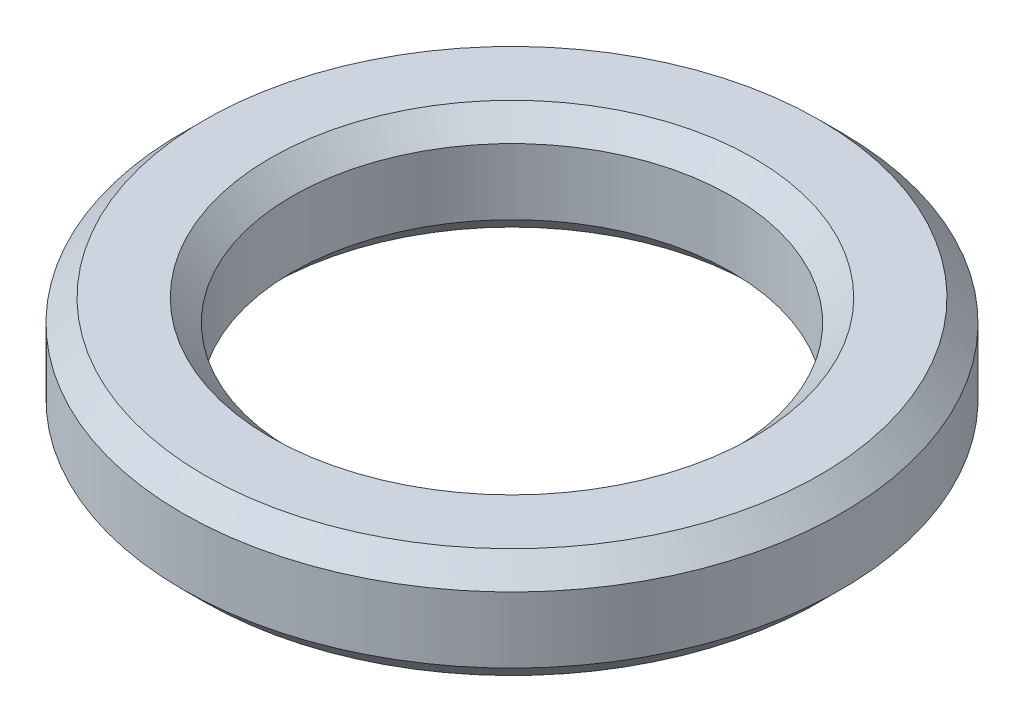
from build123d import *

# Parameters (mm, degrees)
SKETCH1_R           = 15
SKETCH1_R_2         = 10
EXTRUDE_THIN1_DEPTH = 5
CHAMFER1_SIZE       = 1


with BuildPart() as part:
    # Sketch1 → Extrude-Thin1 (new body)
    with BuildSketch(Plane(origin=(0, 0, 0), x_dir=(1, 0, 0), z_dir=(0, 1, 0))):
        Circle(SKETCH1_R)
        Circle(SKETCH1_R_2, mode=Mode.SUBTRACT)
    extrude(amount=EXTRUDE_THIN1_DEPTH)

    # Chamfer1
    chamfer1_edges = [part.edges().sort_by_distance(p)[0] for p in [
        (-15, 0, 0),
        (-10, 0, 0),
        (-15, 5, 0),
        (-10, 5, 0),
    ]]
    chamfer(chamfer1_edges, length=CHAMFER1_SIZE)


solid = part.part
